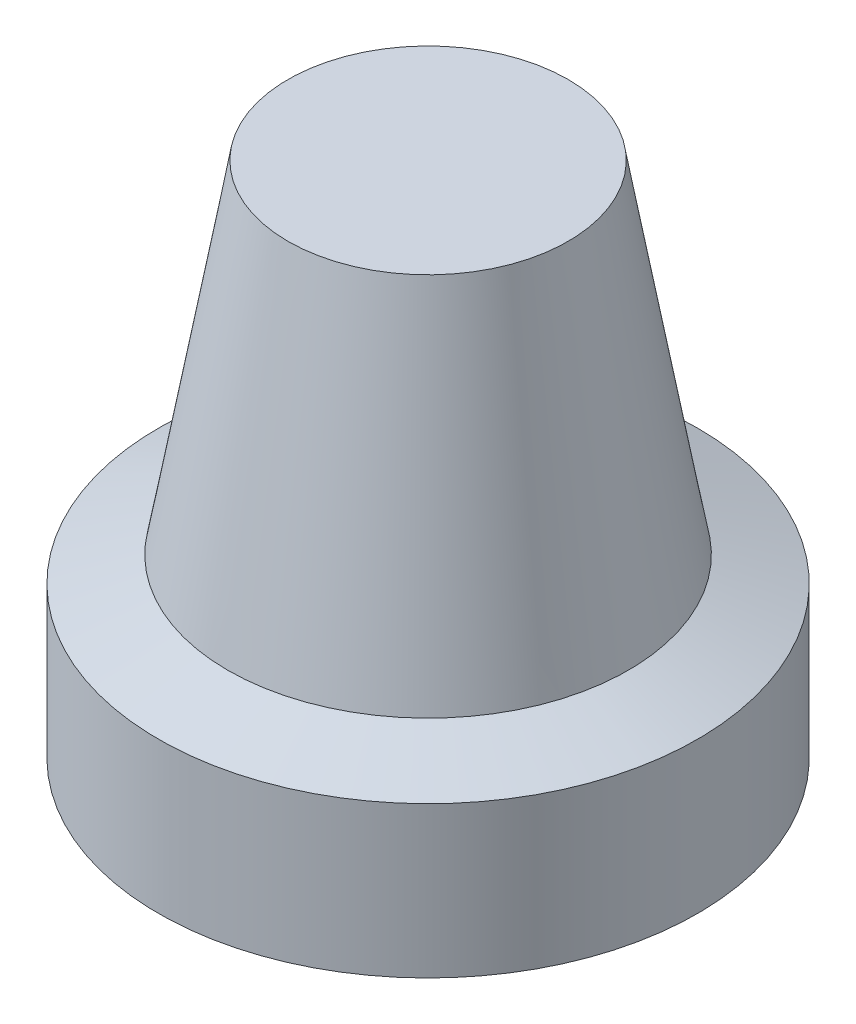
from build123d import *

# Parameters (mm, degrees)
SKETCH3_R          = 3
CUT_EXTRUDE1_DEPTH = 10


with BuildPart() as part:
    # Sketch2 → Revolve1 (revolve)
    with BuildSketch(Plane.XY):
        Polygon((0, 0), (5, 0), (10.5, -2), (12.5, -2), (12.5, 5), (9.291654184, 6.167742378), (6.5, 22), (0, 22), align=None)
    revolve(axis=Axis((0, -4.501967694, 0), (0, 1, 0)))

    # Sketch3 → Cut-Extrude1 (cut)
    with BuildSketch(Plane.XZ):
        Circle(SKETCH3_R)
    extrude(amount=-CUT_EXTRUDE1_DEPTH, mode=Mode.SUBTRACT)


solid = part.part
